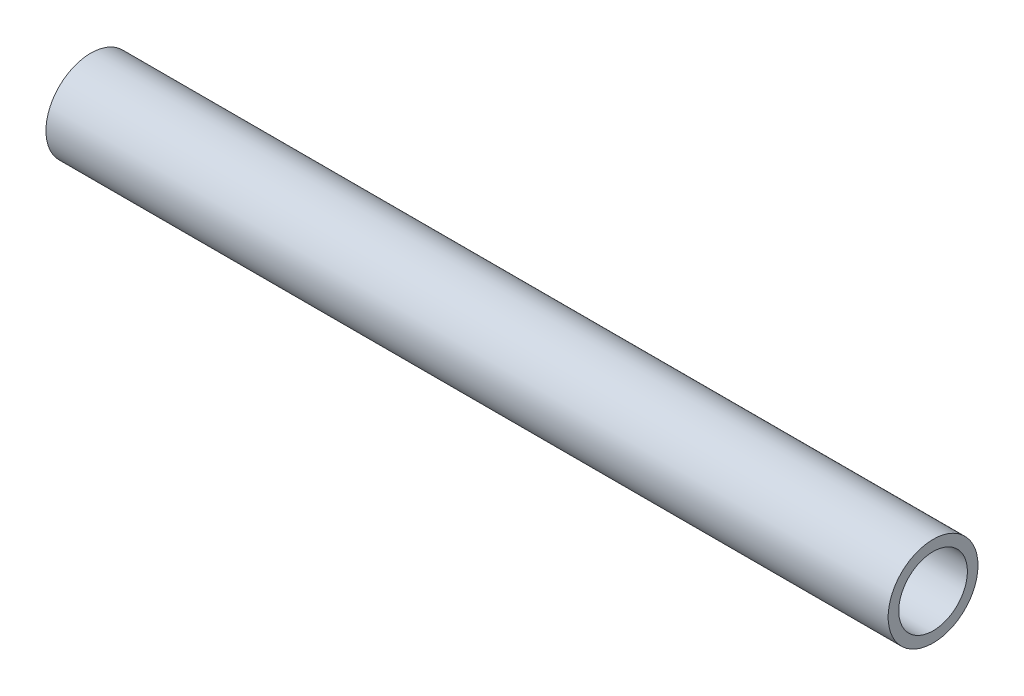
from build123d import *

# Parameters (mm, degrees)
SKETCH1_R           = 8
SKETCH1_R_2         = 6.11476785
BOSS_EXTRUDE1_DEPTH = 150


with BuildPart() as part:
    # Sketch1 → Boss-Extrude1 (new body)
    with BuildSketch(Plane(origin=(0, 0, 0), x_dir=(0, 0, -1), z_dir=(1, 0, 0))):
        Circle(SKETCH1_R)
        Circle(SKETCH1_R_2, mode=Mode.SUBTRACT)
    extrude(amount=BOSS_EXTRUDE1_DEPTH)


solid = part.part
